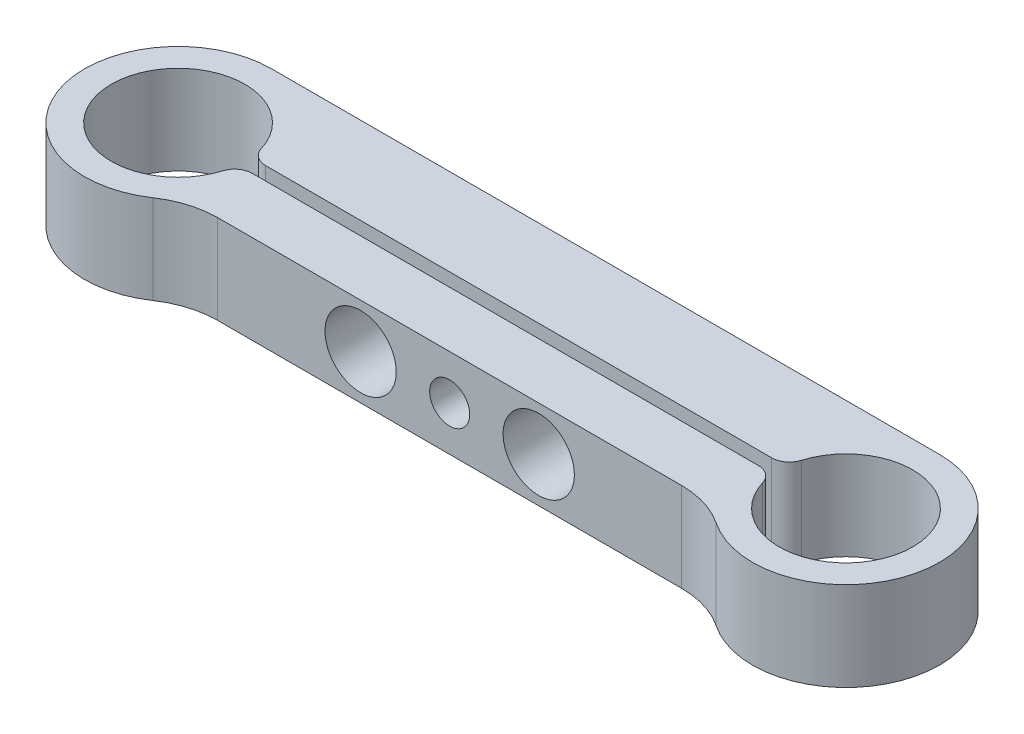
from build123d import *

# Parameters (mm, degrees)
EXTRUDE_1_DEPTH           = 10
HOLE_WIZARD_8_0_8_1_D     = 8
HOLE_WIZARD_8_0_8_1_DEPTH = 6.25
HOLE_WIZARD_M41_D         = 4.5
HOLE_WIZARD_M41_DEPTH     = 11
HOLE_WIZARD_M41_TIP       = 1.351936393
HOLE_WIZARD_M42_D         = 4.5
HOLE_WIZARD_M42_DEPTH     = 6.25
M4X0_72_D                 = 3.3
FILLET_2_R                = 10
FILLET_3_R                = 2


with BuildPart() as part:
    # Эскиз1 → Бобышка-Вытянуть1 (new body)
    with BuildSketch(Plane(origin=(0, 0, 0), x_dir=(1, 0, 0), z_dir=(0, 1, 0))):
        with BuildLine():
            Line((67.173762079, -7), (7.826237921, -7))
            ThreePointArc((7.826237921, -7), (-9.585144756, -4.28660705), (0, 10.5))
            Line((0, 10.5), (75, 10.5))
            ThreePointArc((75, 10.5), (84.585144756, -4.28660705), (67.173762079, -7))
        make_face()
        with BuildLine():
            Line((7.462405778, -0.75), (67.537594222, -0.75))
            ThreePointArc((67.537594222, -0.75), (82.5, 0), (67.537594222, 0.75))
            Line((67.537594222, 0.75), (7.462405778, 0.75))
            ThreePointArc((7.462405778, 0.75), (-7.5, 0), (7.462405778, -0.75))
        make_face(mode=Mode.SUBTRACT)
    extrude(amount=EXTRUDE_1_DEPTH)

    # Диаметр отверстия Ø8.0 (8)1
    with Locations(Plane.XY.offset(7)):
        with Locations((27.5, 5), (47.5, 5)):
            Hole(HOLE_WIZARD_8_0_8_1_D / 2, depth=HOLE_WIZARD_8_0_8_1_DEPTH)

    # Отверстие с зазором M41
    with Locations(Plane.XY.offset(-0.75)):
        with Locations((47.5, 5), (27.5, 5)):
            Hole(HOLE_WIZARD_M41_D / 2, depth=HOLE_WIZARD_M41_DEPTH)
            with Locations((0, 0, -(HOLE_WIZARD_M41_DEPTH + HOLE_WIZARD_M41_TIP / 2))):  # 118° drill point
                Cone(0, HOLE_WIZARD_M41_D / 2, HOLE_WIZARD_M41_TIP, mode=Mode.SUBTRACT)

    # Отверстие с зазором M42
    with Locations(Plane.XY.offset(7)):
        with Locations((37.5, 5)):
            Hole(HOLE_WIZARD_M42_D / 2, depth=HOLE_WIZARD_M42_DEPTH)

    # Отверстие обработанное метчиком M4x0.72 (through all)
    with Locations(Plane.XY.offset(-0.75)):
        with Locations((37.5, 5)):
            Hole(M4X0_72_D / 2)

    # Скругление2
    fillet_2_edges = [part.edges().sort_by_distance(p)[0] for p in [
        (67.173762079, 5, 7),
        (7.826237921, 5, 7),
    ]]
    fillet(fillet_2_edges, radius=FILLET_2_R)

    # Скругление3
    fillet_3_edges = [part.edges().sort_by_distance(p)[0] for p in [
        (7.462405778, 5, -0.75),
        (7.462405778, 5, 0.75),
        (67.537594222, 5, 0.75),
        (67.537594222, 5, -0.75),
    ]]
    fillet(fillet_3_edges, radius=FILLET_3_R)


solid = part.part
